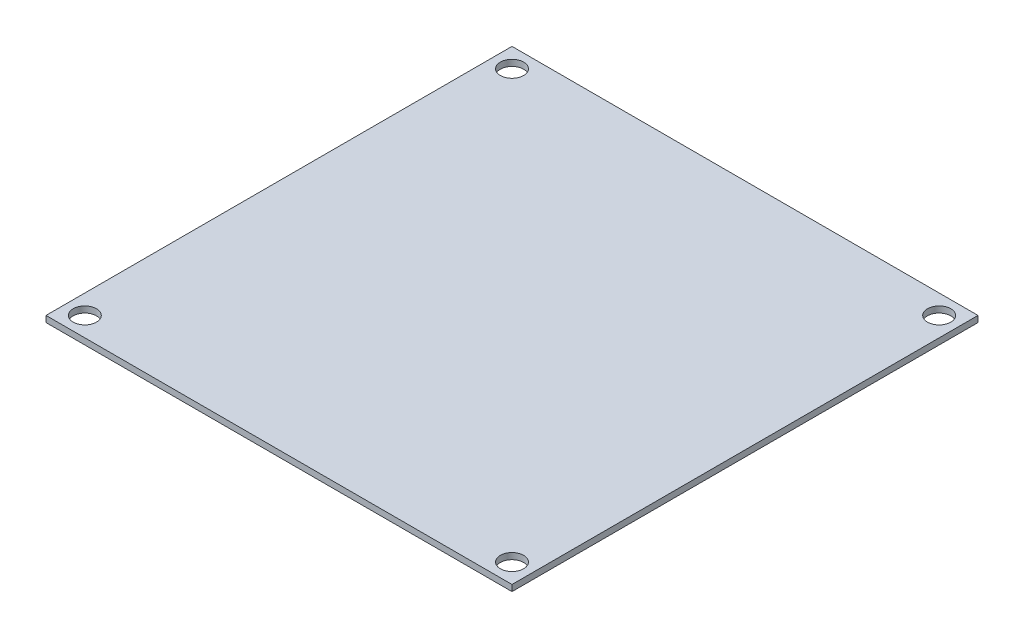
from build123d import *

# Parameters (mm, degrees)
SKETCH1_W                = 60
SKETCH1_H                = 60
BOSS_EXTRUDE1_DEPTH      = 0.8
F_3_0_3_DIAMETER_HOLE1_D = 3


with BuildPart() as part:
    # Sketch1 → Boss-Extrude1 (new body)
    with BuildSketch(Plane(origin=(0, 0, 0), x_dir=(1, 0, 0), z_dir=(0, 1, 0))):
        Rectangle(SKETCH1_W, SKETCH1_H)
    extrude(amount=BOSS_EXTRUDE1_DEPTH)

    # Ø3.0 (3) Diameter Hole1 (through all)
    with Locations(Plane(origin=(0, 0.8, 0), x_dir=(1, 0, 0), z_dir=(0, 1, 0))):
        with Locations((-27.5, 27.5), (27.5, 27.5), (27.5, -27.5), (-27.5, -27.5)):
            Hole(F_3_0_3_DIAMETER_HOLE1_D / 2)


solid = part.part
